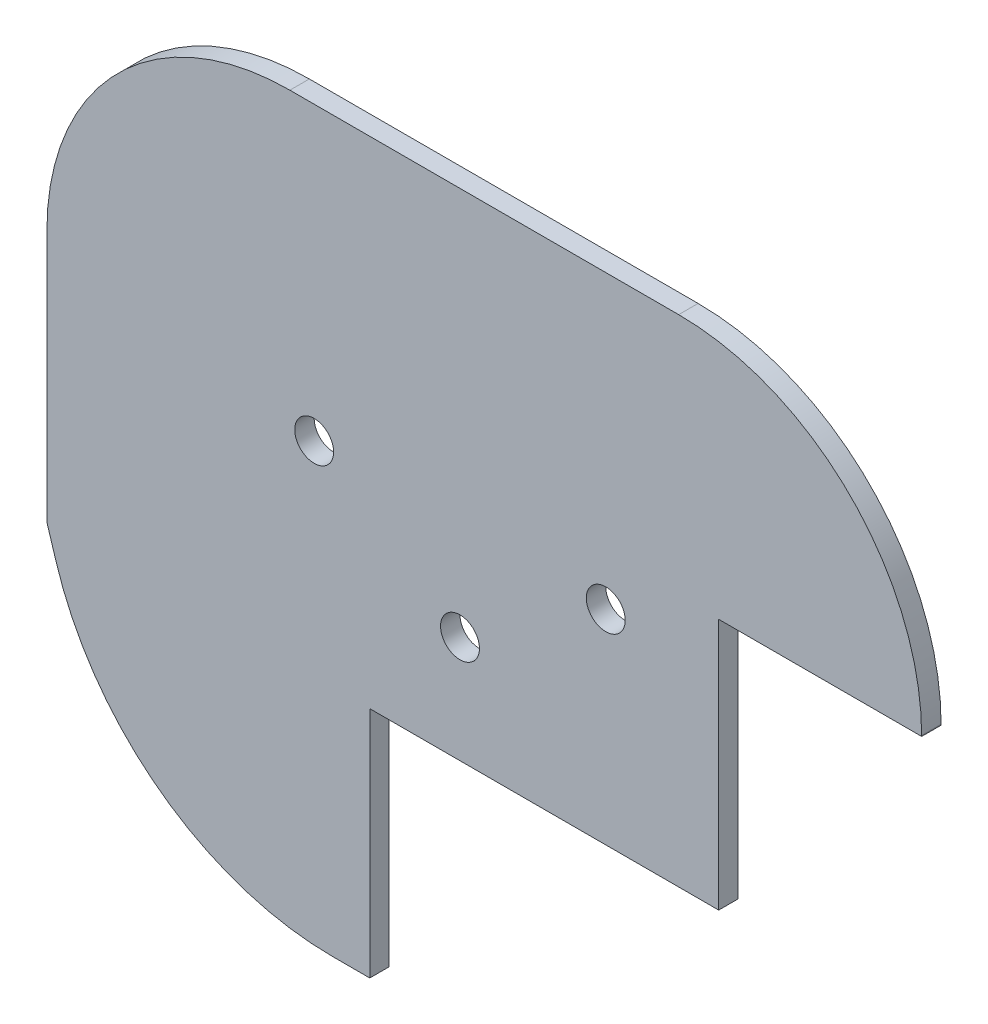
from build123d import *

# Parameters (mm, degrees)
BOSS_EXTRUDE1_DEPTH = 1
SKETCH2_R           = 1
CUT_EXTRUDE1_DEPTH  = 2
BOSS_EXTRUDE3_DEPTH = 2


with BuildPart() as part:
    # Sketch1 → Boss-Extrude1 (new body)
    with BuildSketch(Plane.XY):
        with BuildLine():
            Line((-37.408874503, 0), (-36.935496874, -1.52115571))
            ThreePointArc((-36.935496874, -1.52115571), (-31.538206109, -9.097817453), (-22.7, -12))
            Line((-22.7, -12), (-20.8, -12))
            Line((-20.8, -12), (-20.8, 0))
            Line((-20.8, 0), (-2.848874503, 0))
            Line((-2.848874503, 0), (-2.848874503, 12.956751258))
            Line((-2.848874503, 12.956751258), (6.330544431, 12.956751258))
            Line((6.330544431, 12.956751258), (7.591125497, 12.956751258))
            Line((7.591125497, 12.956751258), (7.591125497, 13))
            ThreePointArc((7.591125497, 13), (3.929960262, 21.838834765), (-4.908874503, 25.5))
            Line((-4.908874503, 25.5), (-24.908874503, 25.5))
            ThreePointArc((-24.908874503, 25.5), (-33.747709268, 21.838834765), (-37.408874503, 13))
            Line((-37.408874503, 13), (-37.408874503, 0))
        make_face()
    extrude(amount=BOSS_EXTRUDE1_DEPTH)

    # Sketch2 → Cut-Extrude1 (cut, through all)
    with BuildSketch(Plane.XY.offset(1)):
        with Locations((-8.658874503, 10.5)):
            Circle(SKETCH2_R)
        with Locations((-23.658874503, 10.5)):
            Circle(SKETCH2_R)
        with Locations((-16.158874503, 5.5)):
            Circle(SKETCH2_R)
    extrude(amount=-CUT_EXTRUDE1_DEPTH, mode=Mode.SUBTRACT)

    # Sketch8 → Boss-Extrude3 (add)
    with BuildSketch(Plane.XY.offset(1)):
        with BuildLine():
            Line((-2.848874503, 12.956751258), (3.166072925, 12.956751258))
            Line((3.166072925, 12.956751258), (3.367034903, 18.000639192))
            ThreePointArc((3.367034903, 18.000639192), (2.849823018, 20.366659135), (1.243261137, 22.178982899))
            ThreePointArc((1.243261137, 22.178982899), (-1.693696517, 23.571902881), (-4.908874503, 24.05))
            Line((-4.908874503, 24.05), (-24.908874503, 24.05))
            ThreePointArc((-24.908874503, 24.05), (-32.722404435, 20.813529932), (-35.958874503, 13))
            Line((-35.958874503, 13), (-35.958874503, 1.543887245))
            ThreePointArc((-35.958874503, 1.543887245), (-35.832184971, 0.056041311), (-35.455764157, -1.388964962))
            Line((-35.455764157, -1.388964962), (-35.389408707, -1.576681154))
            ThreePointArc((-35.389408707, -1.576681154), (-30.47080344, -8.080025204), (-22.7, -10.55))
            Line((-22.7, -10.55), (-21.8, -10.55))
            Line((-21.8, -10.55), (-21.8, -4.322233026))
            ThreePointArc((-21.8, -4.322233026), (-27.267294325, -0.393232372), (-29.358874503, 6.006271182))
            Line((-29.358874503, 6.006271182), (-29.358874503, 10.202170558))
            ThreePointArc((-29.358874503, 10.202170558), (-28.131966709, 13.904649986), (-24.936824853, 16.141774295))
            ThreePointArc((-24.936824853, 16.141774295), (-15.555605997, 17.446766156), (-6.215886942, 15.87199031))
            ThreePointArc((-6.215886942, 15.87199031), (-4.096264622, 14.53396256), (-2.848874503, 12.359765022))
            Line((-2.848874503, 12.359765022), (-2.848874503, 12.956751258))
        make_face()
    extrude(amount=-BOSS_EXTRUDE3_DEPTH)


solid = part.part
